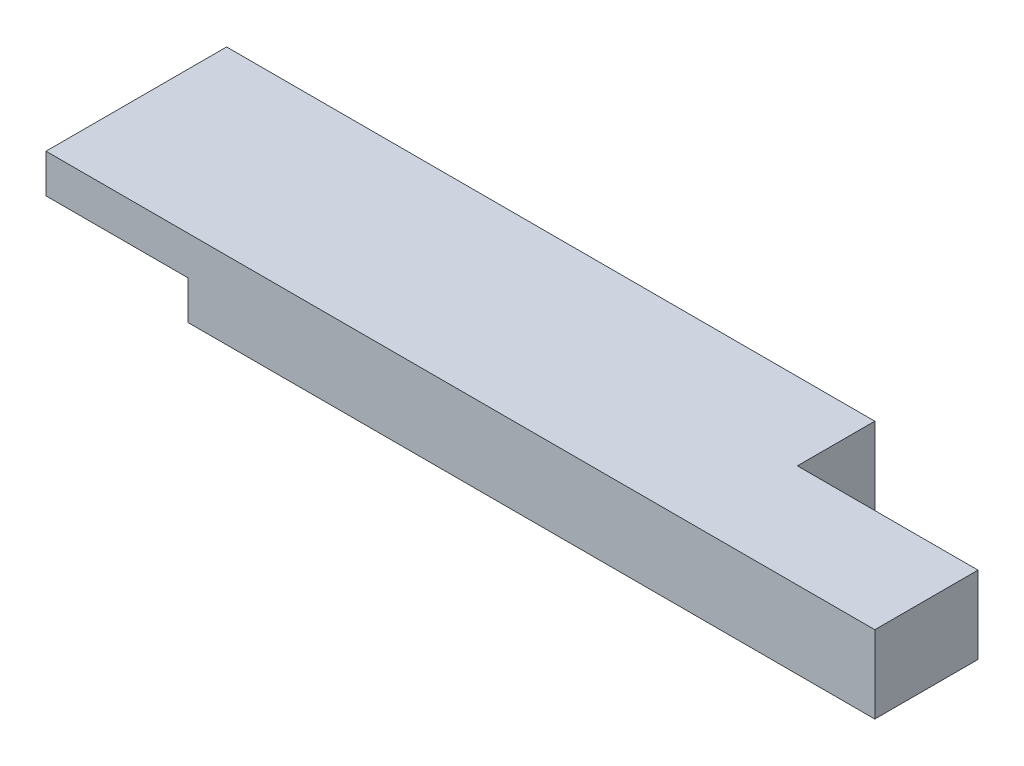
from build123d import *

# Parameters (mm, degrees)
SKETCH1_W           = 407.9875
SKETCH1_H           = 88.9
BOSS_EXTRUDE1_DEPTH = 38.1
SKETCH3_W           = 88.9
SKETCH3_H           = 38.1
CUT_EXTRUDE2_DEPTH  = 39.1
SKETCH4_W           = 69.85
SKETCH4_H           = 19.05
CUT_EXTRUDE3_DEPTH  = 89.9


with BuildPart() as part:
    # Sketch1 → Boss-Extrude1 (new body)
    with BuildSketch(Plane(origin=(0, 0, 0), x_dir=(1, 0, 0), z_dir=(0, 1, 0))):
        with Locations((203.99375, 44.45)):
            Rectangle(SKETCH1_W, SKETCH1_H)
    extrude(amount=BOSS_EXTRUDE1_DEPTH)

    # Sketch3 → Cut-Extrude2 (cut, through all)
    with BuildSketch(Plane(origin=(0, 38.1, 0), x_dir=(1, 0, 0), z_dir=(0, 1, 0))):
        with Locations((363.5375, 69.85)):
            Rectangle(SKETCH3_W, SKETCH3_H)
    extrude(amount=-CUT_EXTRUDE2_DEPTH, mode=Mode.SUBTRACT)

    # Sketch4 → Cut-Extrude3 (cut, through all)
    with BuildSketch(Plane.XY):
        with Locations((34.925, 9.525)):
            Rectangle(SKETCH4_W, SKETCH4_H)
    extrude(amount=-CUT_EXTRUDE3_DEPTH, mode=Mode.SUBTRACT)


solid = part.part
